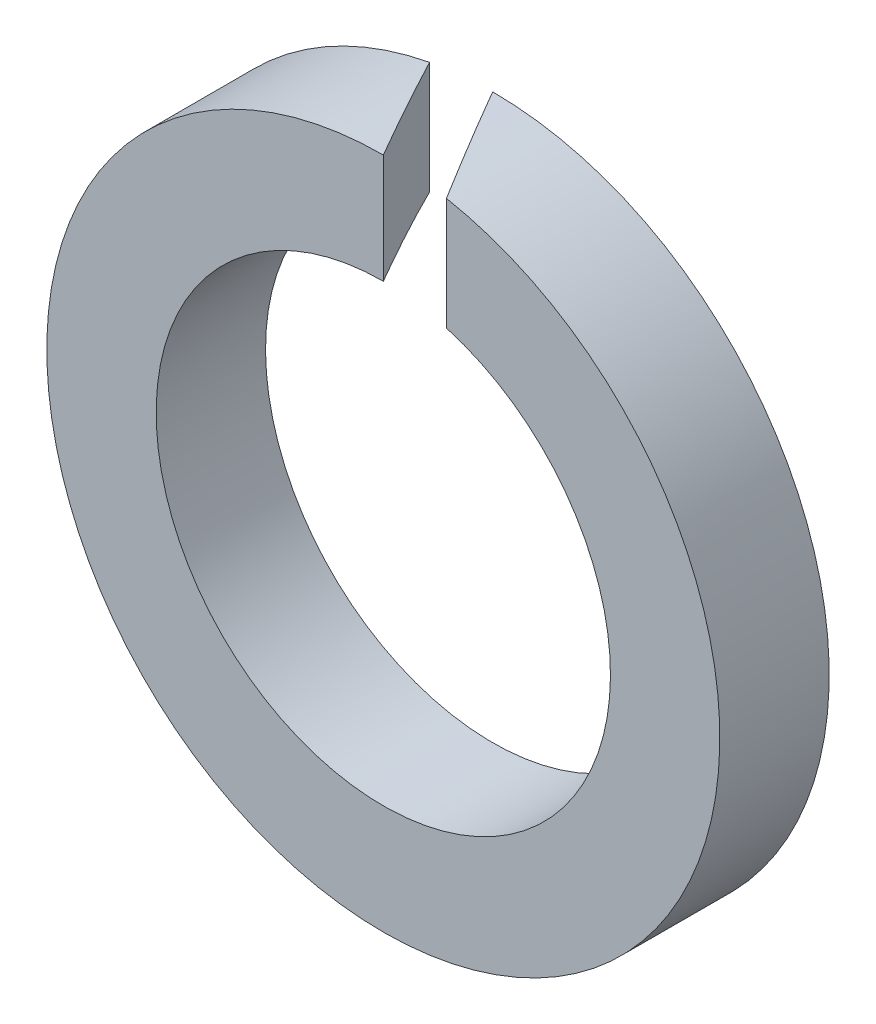
from build123d import *

# Parameters (mm, degrees)
SKETCH1_R          = 4
SKETCH1_R_2        = 2.7
BASE_EXTRUDE_DEPTH = 1.3
CUT_EXTRUDE1_DEPTH = 5


with BuildPart() as part:
    # Sketch1 → Base-Extrude (new body)
    with BuildSketch(Plane.XY):
        Circle(SKETCH1_R)
        Circle(SKETCH1_R_2, mode=Mode.SUBTRACT)
    extrude(amount=-BASE_EXTRUDE_DEPTH)

    # Sketch2 → Cut-Extrude1 (cut, through all)
    with BuildSketch(Plane(origin=(0, 0, 0), x_dir=(1, 0, 0), z_dir=(0, 1, 0))):
        Polygon((0, 1.3), (0.75055535, 0), (0, 0), (-0.75055535, 1.3), align=None)
    extrude(amount=CUT_EXTRUDE1_DEPTH, mode=Mode.SUBTRACT)


solid = part.part
